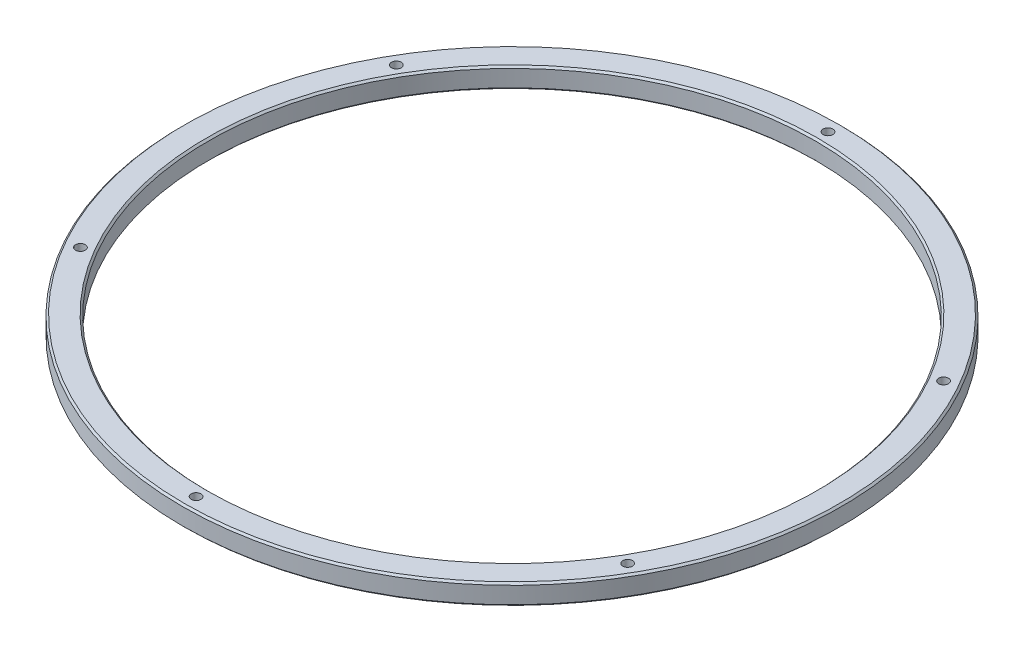
from build123d import *

# Parameters (mm, degrees)
SKETCH1_R             = 161.157000012
SKETCH1_R_2           = 148.457000012
SKETCH1_R_3           = 2.38125
BOSS_EXTRUDE1_DEPTH   = 10
CHAMFER1_SIZE         = 0.889
CHAMFER2_SIZE         = 2.54
CHAMFER2_SIZE2        = 2.131313063
CHAMFER2_PART_2_SIZE  = 2.54
CHAMFER2_PART_2_SIZE2 = 2.131313063
CHAMFER2_PART_3_SIZE  = 2.54
CHAMFER2_PART_3_SIZE2 = 2.131313063


with BuildPart() as part:
    # Sketch1 → Boss-Extrude1 (new body)
    with BuildSketch(Plane(origin=(0, 0, 0), x_dir=(1, 0, 0), z_dir=(0, 1, 0))):
        Circle(SKETCH1_R)
        Circle(SKETCH1_R_2, mode=Mode.SUBTRACT)
        with Locations((0, 154.5)):
            Circle(SKETCH1_R_3, mode=Mode.SUBTRACT)
        with Locations((133.800924885, 77.25)):
            Circle(SKETCH1_R_3, mode=Mode.SUBTRACT)
        with Locations((133.800924885, -77.25)):
            Circle(SKETCH1_R_3, mode=Mode.SUBTRACT)
        with Locations((0, -154.5)):
            Circle(SKETCH1_R_3, mode=Mode.SUBTRACT)
        with Locations((-133.800924885, -77.25)):
            Circle(SKETCH1_R_3, mode=Mode.SUBTRACT)
        with Locations((-133.800924885, 77.25)):
            Circle(SKETCH1_R_3, mode=Mode.SUBTRACT)
    extrude(amount=BOSS_EXTRUDE1_DEPTH)

    # Chamfer1
    chamfer1_edges = [part.edges().sort_by_distance(p)[0] for p in [
        (-161.157000012, 0, 0),
        (-161.157000012, 10, 0),
        (-148.457000012, 0, 0),
        (-148.457000012, 10, 0),
    ]]
    chamfer(chamfer1_edges, length=CHAMFER1_SIZE)

    # Chamfer2
    chamfer2_edges = [part.edges().sort_by_distance(p)[0] for p in [
        (131.419674885, 0, 77.25),
    ]]
    chamfer2_side = [part.faces().sort_by_distance(p)[0] for p in [
        (-155.734936427, 0, 0),
    ]]
    chamfer(chamfer2_edges, length=CHAMFER2_SIZE, length2=CHAMFER2_SIZE2, reference=chamfer2_side[0])

    # Chamfer2 part 2
    chamfer2_part_2_edges = [part.edges().sort_by_distance(p)[0] for p in [
        (-136.182174885, 0, 77.25),
    ]]
    chamfer2_part_2_side = [part.faces().sort_by_distance(p)[0] for p in [
        (-136.182174885, 5, 77.25),
    ]]
    chamfer(chamfer2_part_2_edges, length=CHAMFER2_PART_2_SIZE, length2=CHAMFER2_PART_2_SIZE2, reference=chamfer2_part_2_side[0])

    # Chamfer2 part 3
    chamfer2_part_3_edges = [part.edges().sort_by_distance(p)[0] for p in [
        (-2.38125, 0, -154.5),
    ]]
    chamfer2_part_3_side = [part.faces().sort_by_distance(p)[0] for p in [
        (-2.38125, 5, -154.5),
    ]]
    chamfer(chamfer2_part_3_edges, length=CHAMFER2_PART_3_SIZE, length2=CHAMFER2_PART_3_SIZE2, reference=chamfer2_part_3_side[0])


solid = part.part
